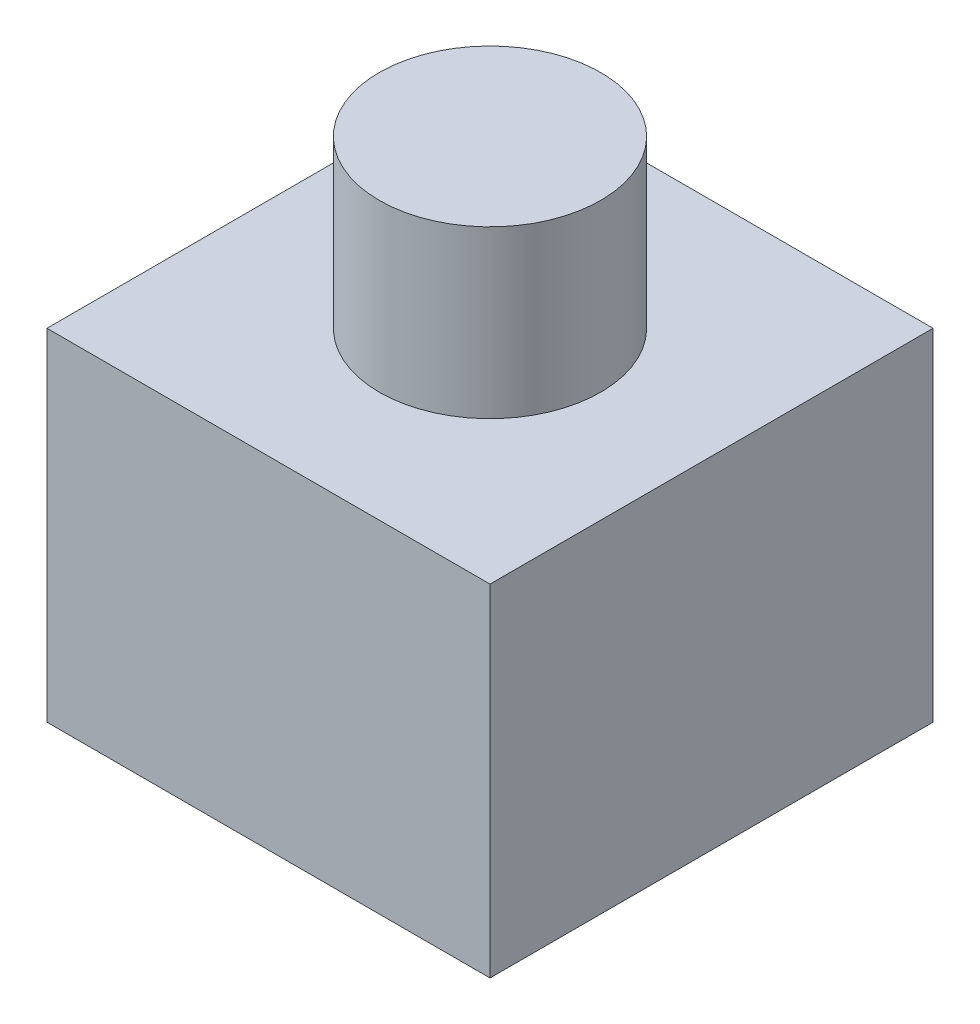
from build123d import *

# Parameters (mm, degrees)
SKETCH1_W           = 25.4
SKETCH1_H           = 25.4
BOSS_EXTRUDE1_DEPTH = 19.558
SKETCH2_R           = 6.35
BOSS_EXTRUDE2_DEPTH = 9.525


with BuildPart() as part:
    # Sketch1 → Boss-Extrude1 (new body)
    with BuildSketch(Plane(origin=(0, 0, 0), x_dir=(1, 0, 0), z_dir=(0, 1, 0))):
        with Locations((12.7, 12.7)):
            Rectangle(SKETCH1_W, SKETCH1_H)
    extrude(amount=BOSS_EXTRUDE1_DEPTH)

    # Sketch2 → Boss-Extrude2 (add)
    with BuildSketch(Plane(origin=(0, 19.558, 0), x_dir=(1, 0, 0), z_dir=(0, 1, 0))):
        with Locations((12.7, 12.7)):
            Circle(SKETCH2_R)
    extrude(amount=BOSS_EXTRUDE2_DEPTH)


solid = part.part
